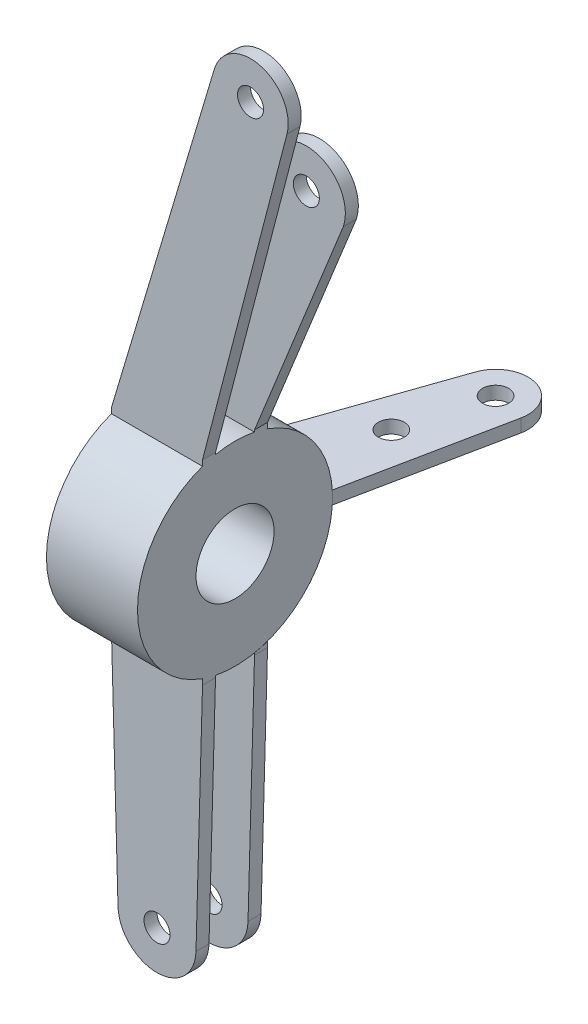
from build123d import *

# Parameters (mm, degrees)
SKETCH1_R             = 37.5
SKETCH1_R_2           = 15
BOSS_EXTRUDE1_DEPTH   = 17.5
SKETCH5_R             = 5
BOSS_EXTRUDE3_DEPTH   = 5
BOSS_EXTRUDE3_2_DEPTH = 5
SKETCH4_R             = 5
BOSS_EXTRUDE5_DEPTH   = 5
BOSS_EXTRUDE5_2_DEPTH = 5
SKETCH10_R            = 5
BOSS_EXTRUDE8_DEPTH   = 2.5
BOSS_EXTRUDE9_DEPTH   = 35
BOSS_EXTRUDE10_DEPTH  = 35


with BuildPart() as part:
    # Sketch1 → Boss-Extrude1 (new body, symmetric)
    with BuildSketch(Plane(origin=(0, 0, 0), x_dir=(0, 0, -1), z_dir=(1, 0, 0))):
        Circle(SKETCH1_R)
        Circle(SKETCH1_R_2, mode=Mode.SUBTRACT)
    extrude(amount=BOSS_EXTRUDE1_DEPTH, both=True)



with BuildPart() as body_2:
    # Sketch5 → Boss-Extrude3 (new body)
    with BuildSketch(Plane.XY.offset(-7.5)):
        with BuildLine():
            Line((-17.5, -37.5), (-14.994178744, -127.417856179))
            ThreePointArc((-14.994178744, -127.417856179), (0, -142), (14.994178744, -127.417856179))
            Line((14.994178744, -127.417856179), (17.5, -37.5))
            Line((17.5, -37.5), (-17.5, -37.5))
        make_face()
        with Locations((0, -127)):
            Circle(SKETCH5_R, mode=Mode.SUBTRACT)
    extrude(amount=-BOSS_EXTRUDE3_DEPTH)


with BuildPart() as body_3:
    # Sketch5 → Boss-Extrude3 2 (new body)
    with BuildSketch(Plane.XY.offset(-7.5)):
        with BuildLine():
            Line((-17.5, 37.5), (17.5, 37.5))
            Line((17.5, 37.5), (51.629964252, 122.209648423))
            ThreePointArc((51.629964252, 122.209648423), (42.984432417, 140.927899671), (23.816779492, 133.330582259))
            Line((23.816779492, 133.330582259), (-17.5, 37.5))
        make_face()
        with Locations((37.415445907, 127)):
            Circle(SKETCH5_R, mode=Mode.SUBTRACT)
    extrude(amount=-BOSS_EXTRUDE3_2_DEPTH)


with BuildPart() as body_4:
    # Sketch4 → Boss-Extrude5 (new body)
    with BuildSketch(Plane.XY.offset(7.5)):
        with BuildLine():
            Line((-17.5, -37.5), (-14.994178744, -127.417856179))
            ThreePointArc((-14.994178744, -127.417856179), (0, -142), (14.994178744, -127.417856179))
            Line((14.994178744, -127.417856179), (17.5, -37.5))
            Line((17.5, -37.5), (-17.5, -37.5))
        make_face()
        with Locations((0, -127)):
            Circle(SKETCH4_R, mode=Mode.SUBTRACT)
    extrude(amount=BOSS_EXTRUDE5_DEPTH)


with BuildPart() as body_5:
    # Sketch4 → Boss-Extrude5 2 (new body)
    with BuildSketch(Plane.XY.offset(7.5)):
        with BuildLine():
            Line((-17.5, 37.5), (17.5, 37.5))
            Line((17.5, 37.5), (49.97768135, 162.205466156))
            ThreePointArc((49.97768135, 162.205466156), (39.857524308, 179.809052463), (22.07719266, 170.002746536))
            Line((22.07719266, 170.002746536), (-17.5, 37.5))
        make_face()
        with Locations((35.95827062, 165.856612881)):
            Circle(SKETCH4_R, mode=Mode.SUBTRACT)
    extrude(amount=BOSS_EXTRUDE5_2_DEPTH)


with BuildPart() as body_6:
    # Sketch10 → Boss-Extrude8 (new body, symmetric)
    with BuildSketch(Plane(origin=(0, 0, 0), x_dir=(1, 0, 0), z_dir=(0, 1, 0))):
        with BuildLine():
            Line((-17.5, 37.5), (17.5, 37.5))
            Line((17.5, 37.5), (29.756996459, 97.671263278))
            ThreePointArc((29.756996459, 97.671263278), (20.81485241, 112.22109988), (5.701063799, 104.269176894))
            Line((5.701063799, 104.269176894), (-17.5, 37.5))
        make_face()
        with Locations((17.508535112, 100.166297272)):
            Circle(SKETCH10_R, mode=Mode.SUBTRACT)
        with Locations((8.754267556, 68.833148636)):
            Circle(SKETCH10_R, mode=Mode.SUBTRACT)
    extrude(amount=BOSS_EXTRUDE8_DEPTH, both=True)

    # Sketch11 → Boss-Extrude9 (add)
    with BuildSketch(Plane(origin=(17.5, 0, 0), x_dir=(0, 0, -1), z_dir=(1, 0, 0))):
        Polygon((37.5, -2.5), (34.44981399, -2.5), (37.479028687, -1.253957217), (34.556673216, 2.5), (37.5, 2.5), align=None)
    extrude(amount=-BOSS_EXTRUDE9_DEPTH)


with BuildPart() as part_1:
    add(part.part)

    add(body_2.part)  # Boss-Extrude10 merges body 2

    add(body_3.part)  # Boss-Extrude10 merges body 3

    add(body_4.part)  # Boss-Extrude10 merges body 4

    add(body_5.part)  # Boss-Extrude10 merges body 5
    # Sketch7 → Boss-Extrude10 (add)
    with BuildSketch(Plane(origin=(17.5, 0, 0), x_dir=(0, 0, -1), z_dir=(1, 0, 0))):
        with BuildLine():
            Line((-7.5, 37.5), (-12.5, 37.5))
            Line((-12.5, 37.5), (-12.5, 35.355339059))
            ThreePointArc((-12.5, 35.355339059), (-10.024018514, 36.135426562), (-7.5, 36.742346142))
            Line((-7.5, 36.742346142), (-7.5, 37.5))
        make_face()
        with BuildLine():
            Line((7.5, 37.5), (7.5, 36.742346142))
            ThreePointArc((7.5, 36.742346142), (10.024018514, 36.135426562), (12.5, 35.355339059))
            Line((12.5, 35.355339059), (12.5, 37.5))
            Line((12.5, 37.5), (7.5, 37.5))
        make_face()
        with BuildLine():
            Line((7.5, -36.742346142), (7.5, -37.5))
            Line((7.5, -37.5), (12.5, -37.5))
            Line((12.5, -37.5), (12.5, -35.355339059))
            ThreePointArc((12.5, -35.355339059), (10.025738696, -36.141627621), (7.5, -36.742346142))
        make_face()
        with BuildLine():
            Line((-12.5, -37.5), (-7.5, -37.5))
            Line((-7.5, -37.5), (-7.5, -36.742346142))
            ThreePointArc((-7.5, -36.742346142), (-10.024018514, -36.135426562), (-12.5, -35.355339059))
            Line((-12.5, -35.355339059), (-12.5, -37.5))
        make_face()
    extrude(amount=-BOSS_EXTRUDE10_DEPTH)


solid = Compound([body_6.part, part_1.part])
